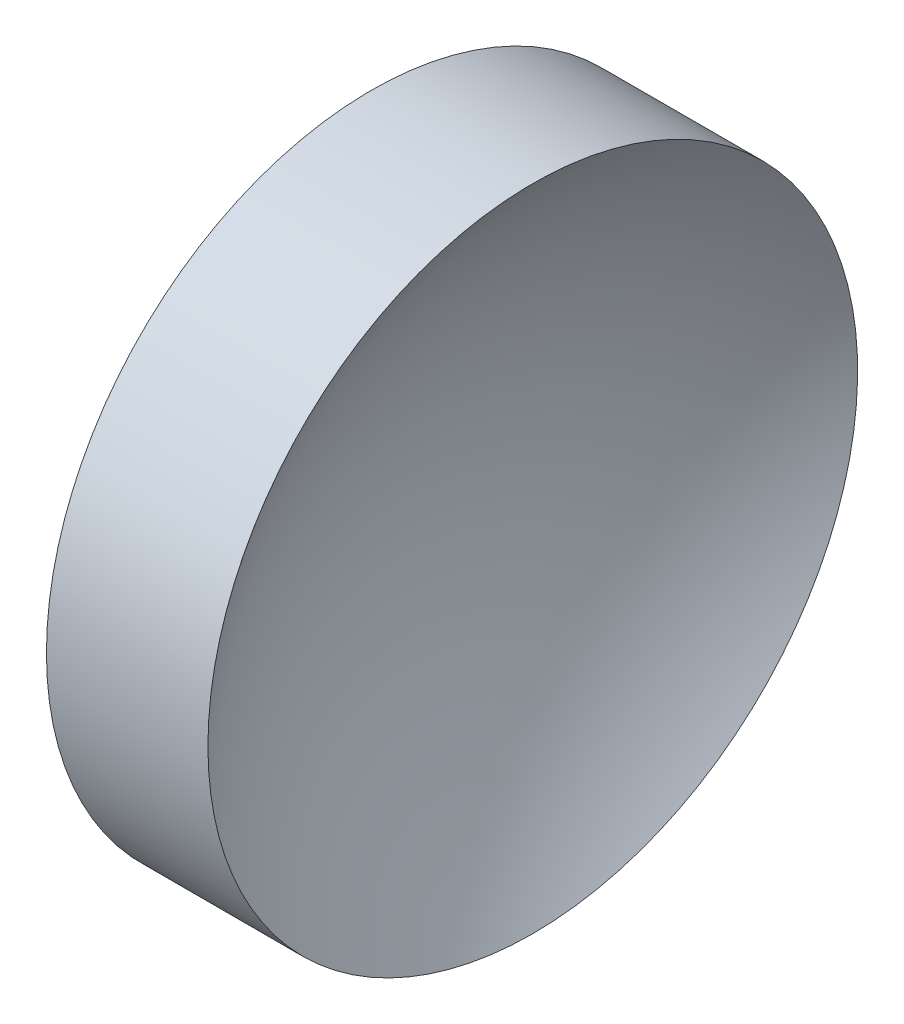
from build123d import *


with BuildPart() as part:
    # 草图1 → 旋转1 (revolve)
    with BuildSketch(Plane.XY, mode=Mode.PRIVATE) as revolve_1_sk:
        with BuildLine():
            Line((57.532337053, 32.610768129), (57.532337053, 45.110768129))
            Line((57.532337053, 45.110768129), (63.745412158, 45.110768129))
            ThreePointArc((63.745412158, 45.110768129), (60.613931406, 39.206221143), (59.532337053, 32.610768129))
            Line((59.532337053, 32.610768129), (57.532337053, 32.610768129))
        make_face()
    revolve(revolve_1_sk.sketch.rotate(Axis((56.10091508, 32.610768129, 0), (1, 0, 0)), 180), axis=Axis((56.10091508, 32.610768129, 0), (1, 0, 0)))  # turned: the seam where the file's is


solid = part.part
